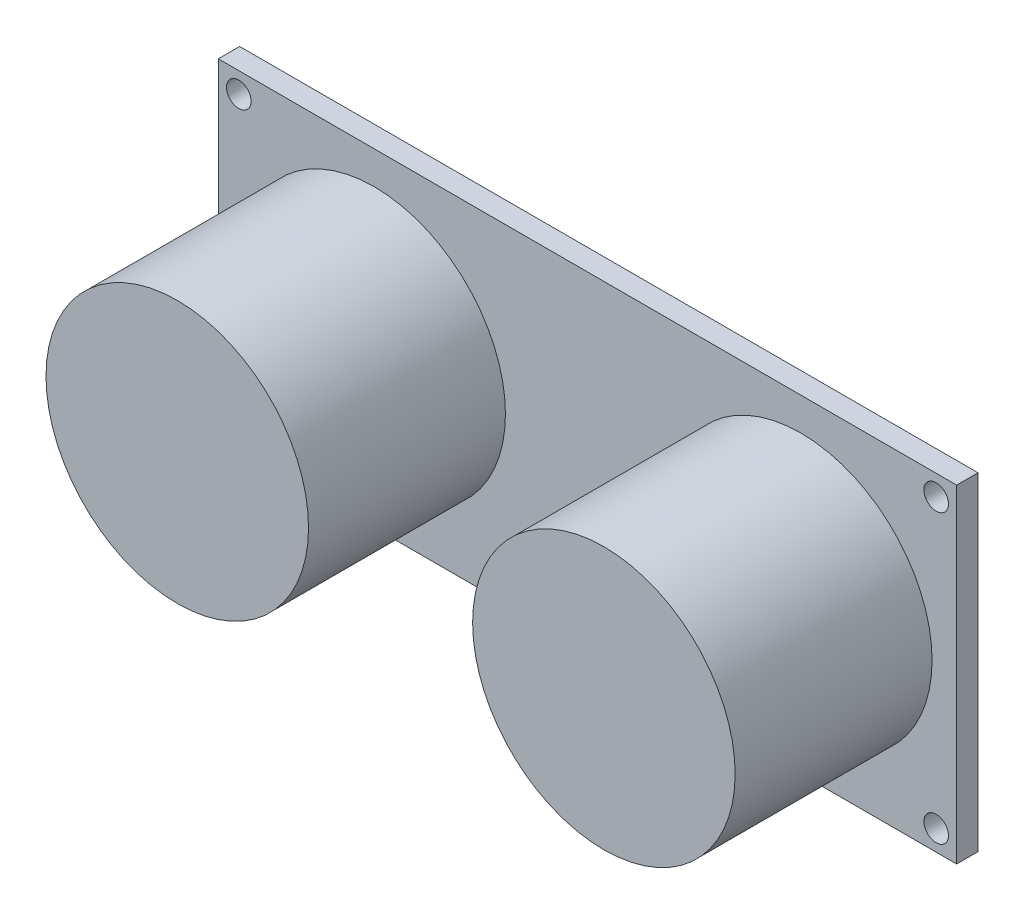
from build123d import *

# Parameters (mm, degrees)
SKETCH_1_W             = 45
SKETCH_1_H             = 20
SKETCH_1_R             = 0.75
EXTRUDE_1_DEPTH        = 1.3
SKETCH_2_R             = 8
EXTRUDE_2_DEPTH        = 12
SKETCH_3_W             = 2.5
SKETCH_3_H             = 2.5
EXTRUDE_3_DEPTH        = 2.5
SKETCH_5_W             = 0.6
SKETCH_5_H             = 0.6
PATTERN_LINEAR_3_COUNT = 4
PATTERN_LINEAR_3_PITCH = 2.54


with BuildPart() as part:
    # 草图1 → 凸台-拉伸1 (new body)
    with BuildSketch(Plane.XY):
        Rectangle(SKETCH_1_W, SKETCH_1_H)
        with Locations((-21.25, 8.75)):
            Circle(SKETCH_1_R, mode=Mode.SUBTRACT)
        with Locations((21.25, 8.75)):
            Circle(SKETCH_1_R, mode=Mode.SUBTRACT)
        with Locations((21.25, -8.75)):
            Circle(SKETCH_1_R, mode=Mode.SUBTRACT)
        with Locations((-21.25, -8.75)):
            Circle(SKETCH_1_R, mode=Mode.SUBTRACT)
    extrude(amount=EXTRUDE_1_DEPTH)

    # 草图2 → 凸台-拉伸2 (add)
    with BuildSketch(Plane.XY.offset(1.3)):
        with Locations((-13, 0)):
            Circle(SKETCH_2_R)
        with Locations((13, 0)):
            Circle(SKETCH_2_R)
    extrude(amount=EXTRUDE_2_DEPTH)

    # 草图3 → 凸台-拉伸3 (add)
    with BuildSketch(Plane(origin=(0, 0, 0), x_dir=(-1, 0, 0), z_dir=(0, 0, -1))):
        with Locations((3.75, -8.75)):
            Rectangle(SKETCH_3_W, SKETCH_3_H)
    extrude_3 = extrude(amount=EXTRUDE_3_DEPTH)

    # 扫描1: sweep along a path in 草图4
    with BuildLine(Plane.ZY.offset(3.75)) as sweep_1_path:
        Line((-2.5, -8.75), (-3.2, -8.75))
        ThreePointArc((-3.2, -8.75), (-3.553553391, -8.896446609), (-3.7, -9.25))
        Line((-3.7, -9.25), (-3.7, -16.45))
    # 草图5 → 扫描1 (sweep)
    with BuildSketch(Plane(origin=(0, 0, -2.5), x_dir=(-1, 0, 0), z_dir=(0, 0, -1))):
        with Locations((3.75, -8.75)):
            Rectangle(SKETCH_5_W, SKETCH_5_H)
    sweep_1 = sweep(path=sweep_1_path.line)

    # 阵列(线性)3: 凸台-拉伸3, 扫描1 ×4
    with Locations(*[(i * PATTERN_LINEAR_3_PITCH, 0, 0) for i in range(1, PATTERN_LINEAR_3_COUNT)]):
        add(extrude_3)
        add(sweep_1)


solid = part.part
